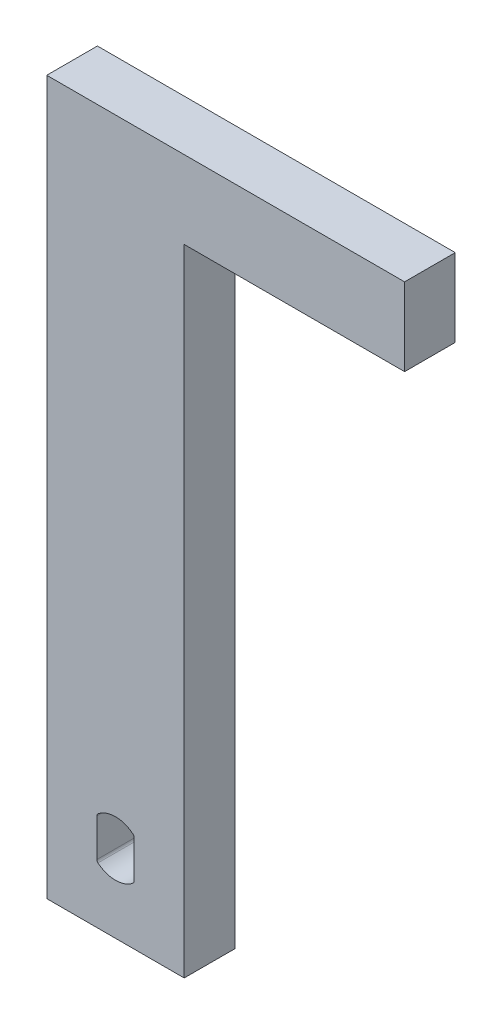
from build123d import *

# Parameters (mm, degrees)
SKETCH1_W           = 13.462
SKETCH1_H           = 69.85
BOSS_EXTRUDE1_DEPTH = 4.9609375
SKETCH2_W           = 4.9609375
SKETCH2_H           = 7.62
BOSS_EXTRUDE2_DEPTH = 21.59
SKETCH3_OUTSIDE_W   = 52.714
SKETCH3_OUTSIDE_H   = 87.512
CUT_EXTRUDE1_DEPTH  = 5.9609375


with BuildPart() as part:
    # Sketch1 → Boss-Extrude1 (new body)
    with BuildSketch(Plane.XY):
        Rectangle(SKETCH1_W, SKETCH1_H)
    extrude(amount=BOSS_EXTRUDE1_DEPTH)

    # Sketch2 → Boss-Extrude2 (add)
    with BuildSketch(Plane(origin=(6.731, 0, 0), x_dir=(0, 0, -1), z_dir=(1, 0, 0))):
        with Locations((-2.48046875, 31.115)):
            Rectangle(SKETCH2_W, SKETCH2_H)
    extrude(amount=BOSS_EXTRUDE2_DEPTH)

    # Sketch3 outside → Cut-Extrude1 (cut, through all)
    with BuildSketch(Plane.XY.offset(4.9609375)):
        with Locations((10.795, 0)):
            Rectangle(SKETCH3_OUTSIDE_W, SKETCH3_OUTSIDE_H)
        Polygon((6.731, -34.925), (6.731, 27.305), (28.321, 27.305), (28.321, 34.925), (-6.731, 34.925), (-6.731, -34.925), align=None, mode=Mode.SUBTRACT)
        with BuildLine():
            Line((-1.825, -29.157786744), (-1.825, -25.451373384))
            ThreePointArc((-1.825, -25.451373384), (-1.79628168, -25.323286499), (-1.715625, -25.219722549))
            ThreePointArc((-1.715625, -25.219722549), (0, -24.604580064), (1.715625, -25.219722549))
            ThreePointArc((1.715625, -25.219722549), (1.79628168, -25.323286499), (1.825, -25.451373384))
            Line((1.825, -25.451373384), (1.825, -29.157786744))
            ThreePointArc((1.825, -29.157786744), (1.79628168, -29.285873629), (1.715625, -29.389437579))
            ThreePointArc((1.715625, -29.389437579), (0, -30.004580064), (-1.715625, -29.389437579))
            ThreePointArc((-1.715625, -29.389437579), (-1.79628168, -29.285873629), (-1.825, -29.157786744))
        make_face()
    extrude(amount=-CUT_EXTRUDE1_DEPTH, mode=Mode.SUBTRACT)


solid = part.part
